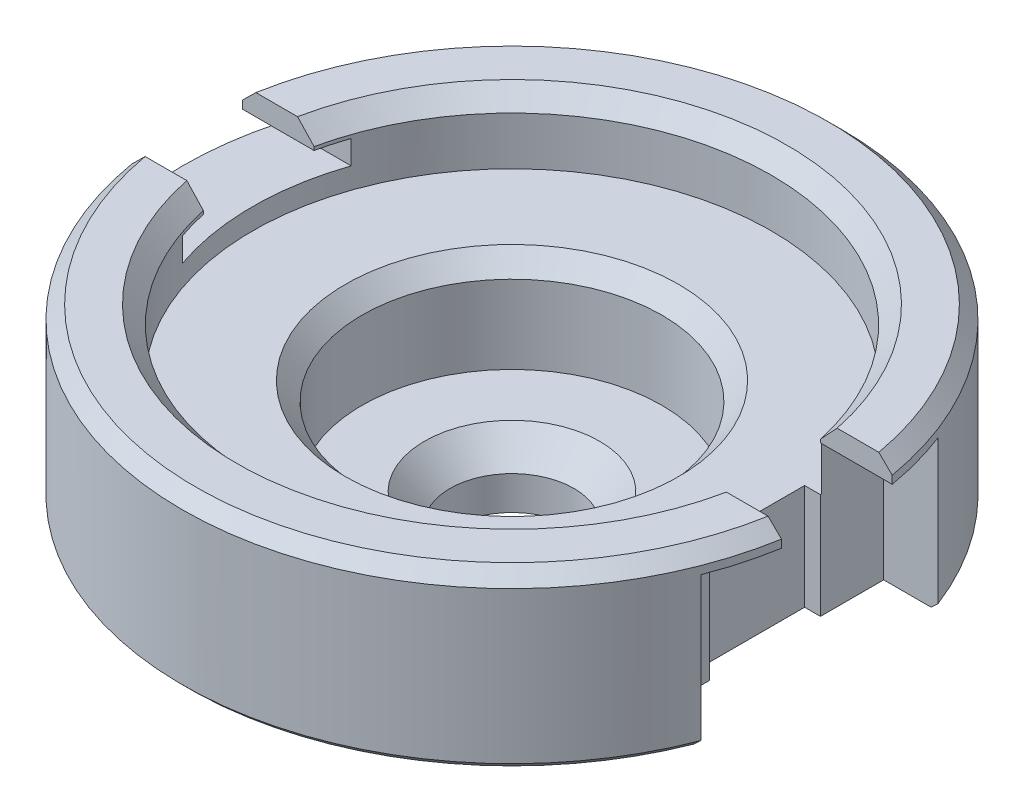
from build123d import *

# Parameters (mm, degrees)
CUT_EXTRUDE1_REACH = 3.25
CUT_EXTRUDE3_REACH = 2.85
SKETCH4_W          = 0.5796936
SKETCH4_H          = 0.42
SKETCH5_W          = 0.593674822
SKETCH5_H          = 0.9
CUT_EXTRUDE4_DEPTH = 0.77


with BuildPart() as part:
    # Sketch1 → Revolve1 (revolve)
    with BuildSketch(Plane.XY):
        Polygon((0.332352738, 0.234317473), (0.235, 0.128), (0.235, 0), (0.304033675, 0), (0.44138561, 0.15), (0.825, 0.15), (0.85, 0.175), (0.85, 0.2), (1.225, 0.2), (1.25, 0.225), (1.25, 0.8), (1.2, 0.85), (1.044713378, 0.85), (0.983447962, 0.783092952), (0.983447962, 0.6), (0.632036734, 0.6), (0.568557305, 0.530675062), (0.568557305, 0.234317473), align=None)
    revolve(axis=Axis((0, 0.85, 0), (0, -1, 0)))

    # Sketch2 → Cut-Extrude1 (cut, up to next)
    with BuildSketch(Plane(origin=(0, 0, 0), x_dir=(0, 0, -1), z_dir=(1, 0, 0)), mode=Mode.PRIVATE) as cut_extrude1_sk1:
        Polygon((0.21, 0.912296329), (0.21, 0.77), (0.32, 0.77), (0.32, 0.68), (-0.32, 0.68), (-0.32, 0.77), (-0.21, 0.77), (-0.21, 0.912296329), align=None)
    cut_extrude1_tool1 = extrude(cut_extrude1_sk1.sketch, amount=-CUT_EXTRUDE1_REACH, mode=Mode.PRIVATE) & part.part
    add(cut_extrude1_tool1.solids().sort_by_distance((0, 0.784145, 0))[0], mode=Mode.SUBTRACT)

    # Sketch4 → Cut-Extrude3 (cut, up to next)
    with BuildSketch(Plane(origin=(0, 0.85, 0), x_dir=(1, 0, 0), z_dir=(0, 1, 0)), mode=Mode.PRIVATE) as cut_extrude3_sk1:
        with Locations((1.1898468, 0)):
            Rectangle(SKETCH4_W, SKETCH4_H)
    cut_extrude3_tool1 = extrude(cut_extrude3_sk1.sketch, amount=-CUT_EXTRUDE3_REACH, mode=Mode.PRIVATE) & part.part
    add(cut_extrude3_tool1.solids().sort_by_distance((1.189847, 0.85, 0))[0], mode=Mode.SUBTRACT)

    # Sketch5 → Cut-Extrude4 (cut)
    with BuildSketch(Plane(origin=(0, 0, 0), x_dir=(1, 0, 0), z_dir=(0, 1, 0))):
        with Locations((1.256837411, 0)):
            Rectangle(SKETCH5_W, SKETCH5_H)
    extrude(amount=CUT_EXTRUDE4_DEPTH, mode=Mode.SUBTRACT)


solid = part.part
